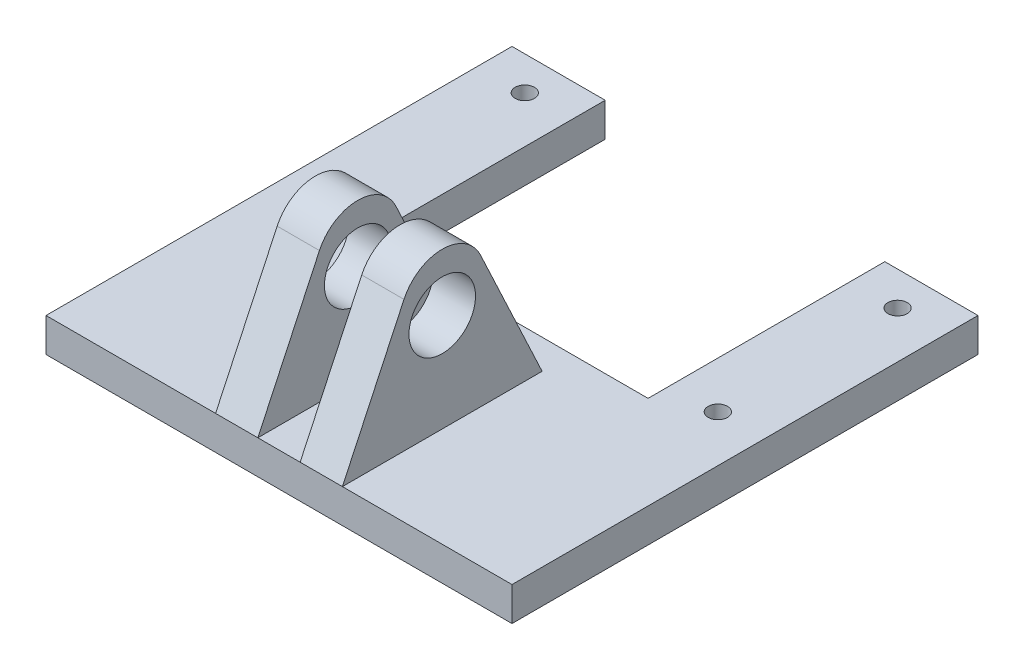
from build123d import *

# Parameters (mm, degrees)
SKETCH1_R                 = 0.725
BOSS_EXTRUDE1_DEPTH       = 2.54
SKETCH2_R                 = 1.651
BOSS_EXTRUDE2_DEPTH       = 4.7625
SKETCH3_W                 = 3.175
SKETCH3_H                 = 15
CUT_EXTRUDE1_DEPTH        = 16
FILLET1_R                 = 3.175
F_5_0MM_DOWEL_HOLE1_D     = 5
F_5_0MM_DOWEL_HOLE1_DEPTH = 20
F_5_0MM_DOWEL_HOLE1_TIP   = 1.502151548


with BuildPart() as part:
    # Sketch1 → Boss-Extrude1 (new body)
    with BuildSketch(Plane(origin=(0, 0, 0), x_dir=(1, 0, 0), z_dir=(0, 1, 0))):
        Polygon((-17.5, 0), (-17.5, 35), (-10.5, 35), (-10.5, 17.22), (10.5, 17.22), (10.5, 35), (17.5, 35), (17.5, 0), align=None)
        with Locations((-14, 32.46)):
            Circle(SKETCH1_R, mode=Mode.SUBTRACT)
        with Locations((-14, 18.96)):
            Circle(SKETCH1_R, mode=Mode.SUBTRACT)
        with Locations((14, 32.46)):
            Circle(SKETCH1_R, mode=Mode.SUBTRACT)
        with Locations((14, 18.96)):
            Circle(SKETCH1_R, mode=Mode.SUBTRACT)
    extrude(amount=BOSS_EXTRUDE1_DEPTH)

    # Sketch2 → Boss-Extrude2 (add, symmetric)
    with BuildSketch(Plane(origin=(0, 0, 0), x_dir=(0, 0, -1), z_dir=(1, 0, 0))):
        Polygon((15, 2.54), (7.5, 18.54), (0, 2.54), align=None)
        with Locations((7.5, 9.94)):
            Circle(SKETCH2_R, mode=Mode.SUBTRACT)
    extrude(amount=BOSS_EXTRUDE2_DEPTH, both=True)

    # Sketch3 → Cut-Extrude1 (cut)
    with BuildSketch(Plane(origin=(0, 2.54, 0), x_dir=(1, 0, 0), z_dir=(0, 1, 0))):
        with Locations((0, 7.5)):
            Rectangle(SKETCH3_W, SKETCH3_H)
    extrude(amount=CUT_EXTRUDE1_DEPTH, mode=Mode.SUBTRACT)

    # Fillet1
    fillet1_edges = [part.edges().sort_by_distance(p)[0] for p in [
        (3.175, 18.54, -7.5),
        (-3.175, 18.54, -7.5),
    ]]
    fillet(fillet1_edges, radius=FILLET1_R)

    # Ø5.0mm Dowel Hole1
    with Locations(Plane.ZY.offset(4.7625)):
        with Locations((-7.5, 9.94)):
            Hole(F_5_0MM_DOWEL_HOLE1_D / 2, depth=F_5_0MM_DOWEL_HOLE1_DEPTH)
            with Locations((0, 0, -(F_5_0MM_DOWEL_HOLE1_DEPTH + F_5_0MM_DOWEL_HOLE1_TIP / 2))):  # 118° drill point
                Cone(0, F_5_0MM_DOWEL_HOLE1_D / 2, F_5_0MM_DOWEL_HOLE1_TIP, mode=Mode.SUBTRACT)


solid = part.part
